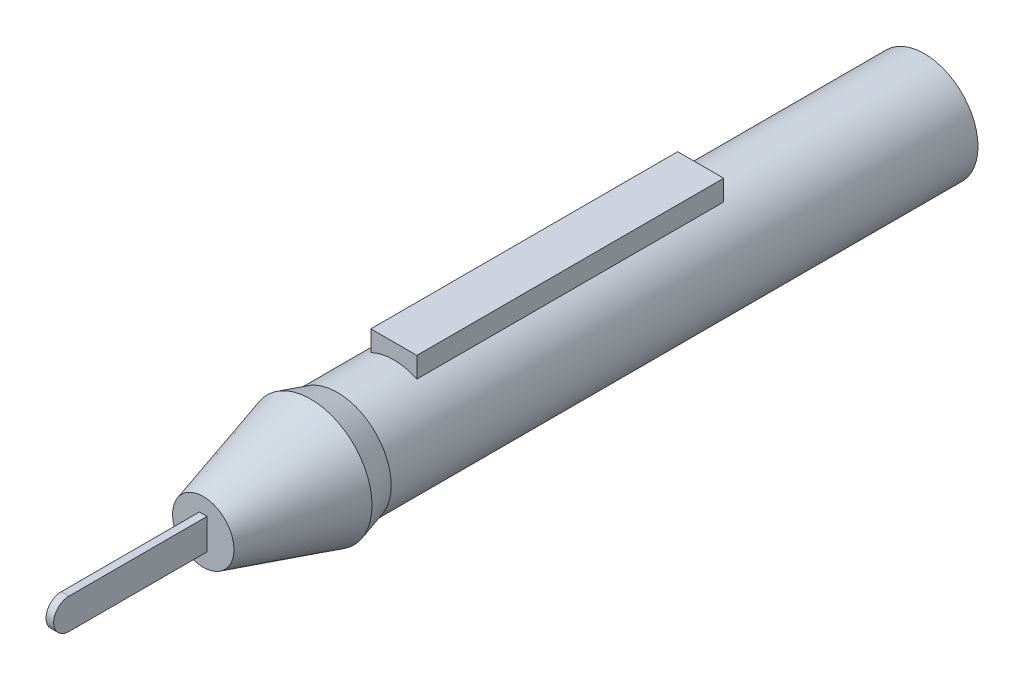
from build123d import *

# Parameters (mm, degrees)
BOSS_EXTRUDE1_DEPTH = 0.5
SKETCH3_W           = 6
SKETCH3_H           = 40
BOSS_EXTRUDE2_DEPTH = 9


with BuildPart() as part:
    # Sketch1 → Boss-Extrude1 (new body, symmetric)
    with BuildSketch(Plane(origin=(0, 0, 0), x_dir=(0, 0, -1), z_dir=(1, 0, 0))):
        with BuildLine():
            Line((2, 2), (20, 2))
            Line((20, 2), (20, -2))
            Line((20, -2), (2, -2))
            ThreePointArc((2, -2), (0, 0), (2, 2))
        make_face()
    extrude(amount=BOSS_EXTRUDE1_DEPTH, both=True)

    # Sketch2 → Revolve1 (revolve)
    with BuildSketch(Plane(origin=(0, 0, 0), x_dir=(0, 0, -1), z_dir=(1, 0, 0))):
        Polygon((20, 0), (20, 4), (34, 8), (37.495076137, 6.998076938), (114, 6.998076938), (114, 0), (34, 0), align=None)
    revolve(axis=Axis((0, 0, -20), (0, 0, -1)))

    # Sketch3 → Boss-Extrude2 (add)
    with BuildSketch(Plane(origin=(0, 0, 0), x_dir=(1, 0, 0), z_dir=(0, 1, 0))):
        with Locations((0, 64.847291261)):
            Rectangle(SKETCH3_W, SKETCH3_H)
    extrude(amount=BOSS_EXTRUDE2_DEPTH)


solid = part.part
